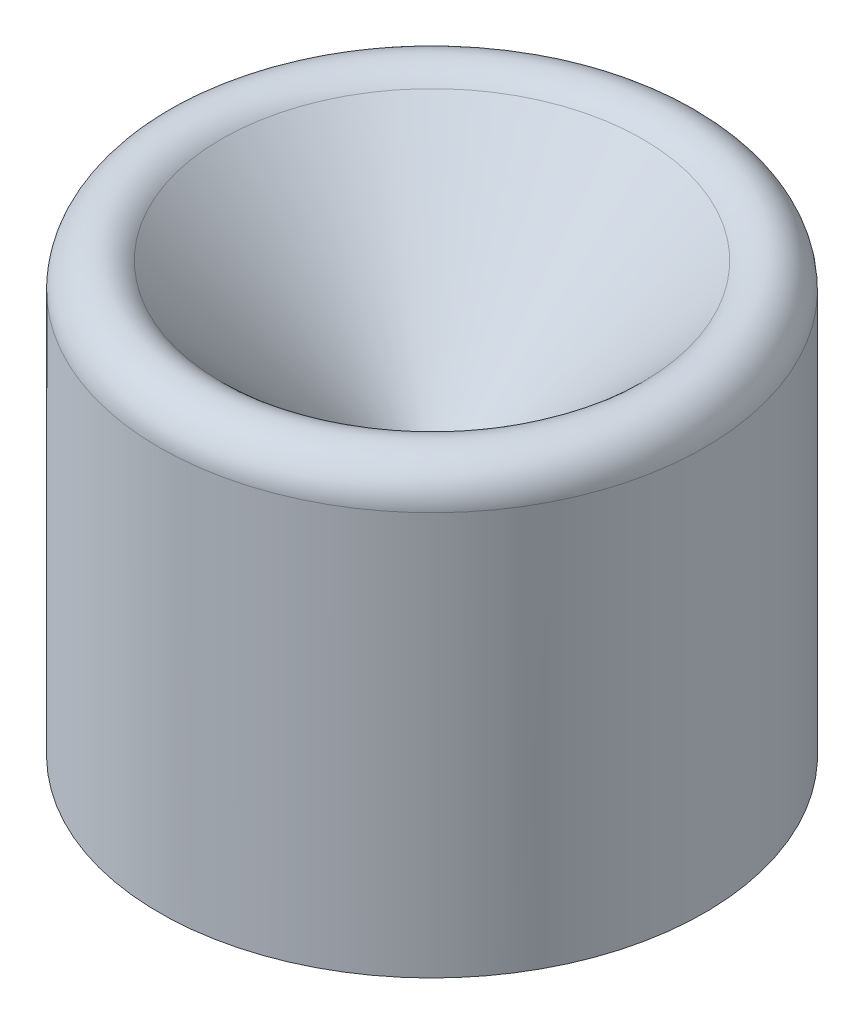
from build123d import *

# Parameters (mm, degrees)
FILLET1_R     = 2
CHAMFER1_SIZE = 1


with BuildPart() as part:
    # Sketch1 → Revolve1 (revolve)
    with BuildSketch(Plane(origin=(0, 0, 0), x_dir=(0, 0, -1), z_dir=(1, 0, 0))):
        Polygon((0, 0), (15, 15), (15, -12), (3, -12), (3, -6), (0, -6), align=None)
    revolve(axis=Axis((0, -6, 0), (0, 1, 0)))

    # Fillet1
    fillet1_edges = [part.edges().sort_by_distance(p)[0] for p in [
        (0, 15, 15),
    ]]
    fillet(fillet1_edges, radius=FILLET1_R)

    # Chamfer1
    chamfer1_edges = [part.edges().sort_by_distance(p)[0] for p in [
        (0, -12, 3),
    ]]
    chamfer(chamfer1_edges, length=CHAMFER1_SIZE)


solid = part.part
